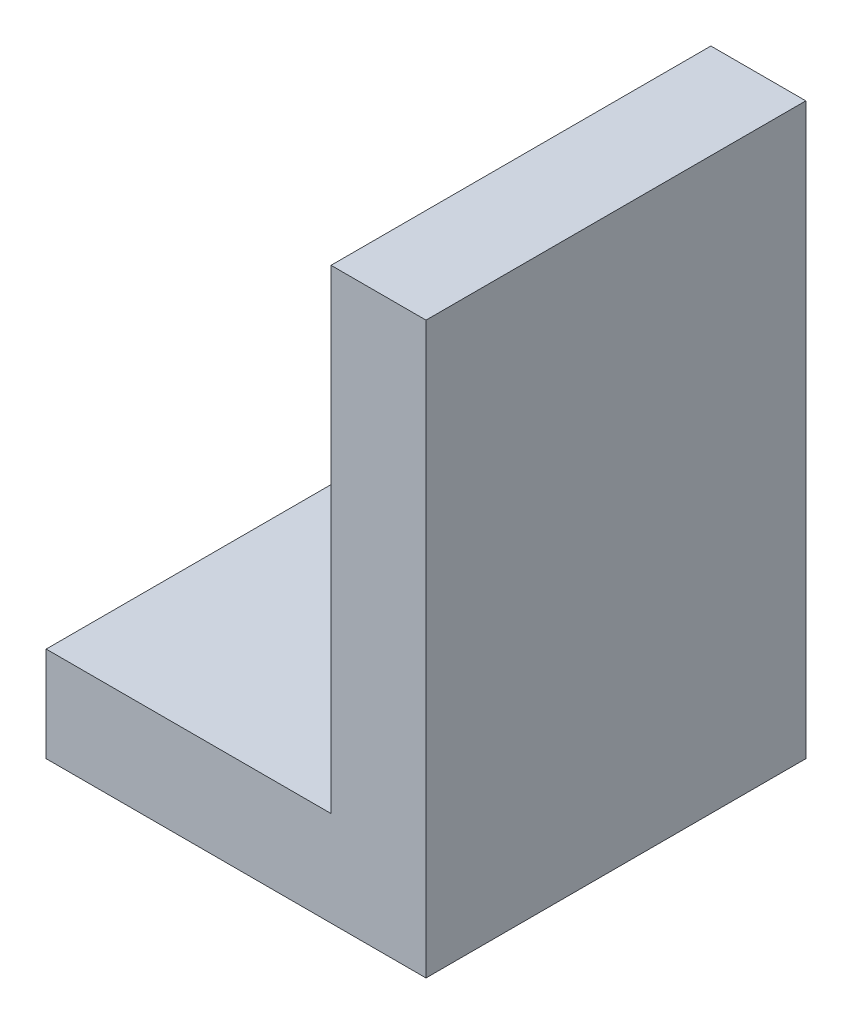
from build123d import *

# Parameters (mm, degrees)
SKETCH1_W           = 40
SKETCH1_H           = 40
BOSS_EXTRUDE1_DEPTH = 10
SKETCH2_W           = 10
SKETCH2_H           = 40
BOSS_EXTRUDE2_DEPTH = 50


with BuildPart() as part:
    # Sketch1 → Boss-Extrude1 (new body)
    with BuildSketch(Plane(origin=(0, 0, 0), x_dir=(1, 0, 0), z_dir=(0, 1, 0))):
        with Locations((-11.64556962, -14.278481013)):
            Rectangle(SKETCH1_W, SKETCH1_H)
    extrude(amount=BOSS_EXTRUDE1_DEPTH)

    # Sketch2 → Boss-Extrude2 (add)
    with BuildSketch(Plane(origin=(0, 10, 0), x_dir=(1, 0, 0), z_dir=(0, 1, 0))):
        with Locations((3.35443038, -14.278481013)):
            Rectangle(SKETCH2_W, SKETCH2_H)
    extrude(amount=BOSS_EXTRUDE2_DEPTH)


solid = part.part
